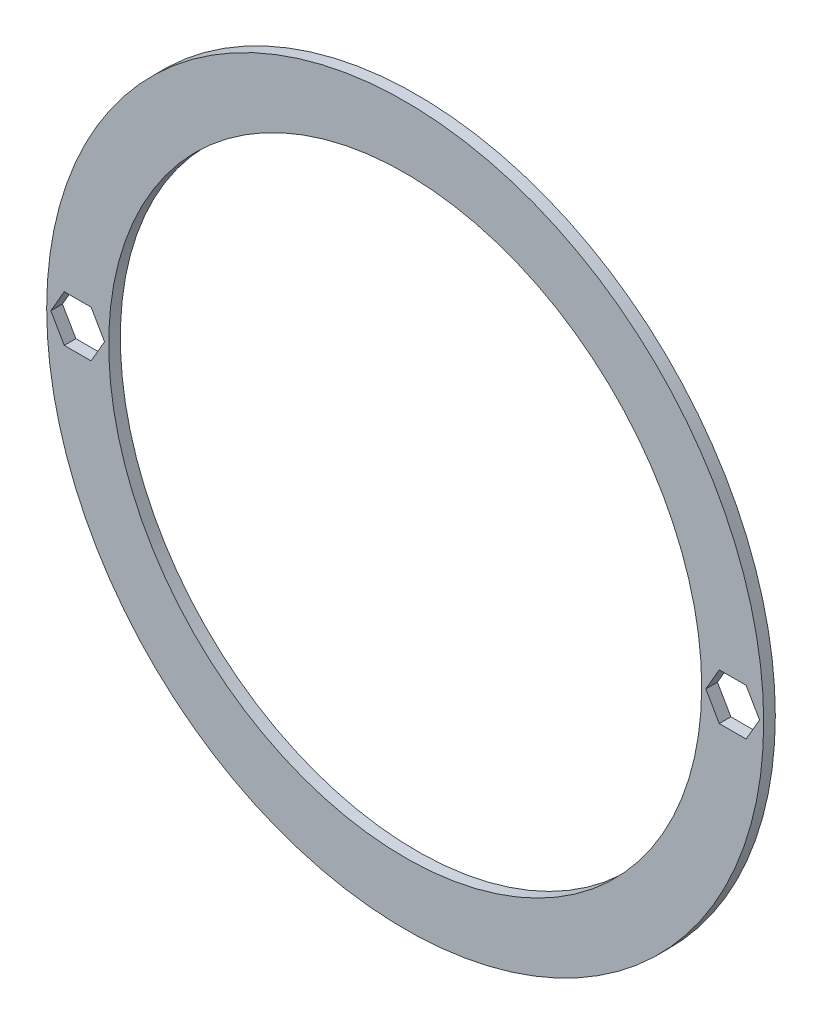
from build123d import *

# Parameters (mm, degrees)
ESQUISSE1_R        = 46.25
ESQUISSE1_R_2      = 38.25
BOSS_EXTRU_1_DEPTH = 1.5


with BuildPart() as part:
    # Esquisse1 → Boss.-Extru.1 (new body)
    with BuildSketch(Plane.XY):
        Circle(ESQUISSE1_R)
        Circle(ESQUISSE1_R_2, mode=Mode.SUBTRACT)
        Polygon((-40.517949192, 3), (-43.982050808, 3), (-45.714101615, 0), (-43.982050808, -3), (-40.517949192, -3), (-38.785898385, 0), align=None, mode=Mode.SUBTRACT)
        Polygon((38.785898385, 0), (40.517949192, 3), (43.982050808, 3), (45.714101615, 0), (43.982050808, -3), (40.517949192, -3), align=None, mode=Mode.SUBTRACT)
    extrude(amount=BOSS_EXTRU_1_DEPTH)


solid = part.part
